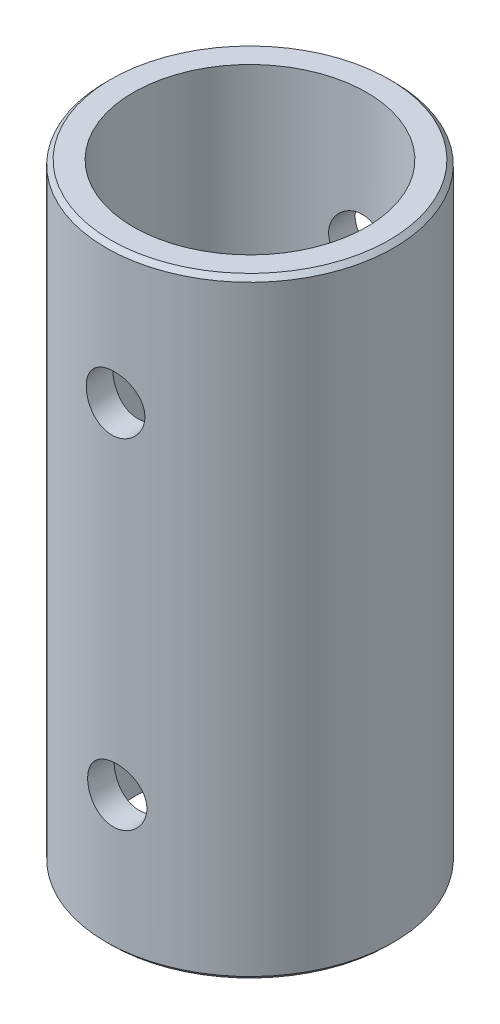
from build123d import *

# Parameters (mm, degrees)
SKETCH1_R               = 7.94
SKETCH1_R_2             = 6.44
BOSS_EXTRUDE1_DEPTH     = 33.7
CHAMFER1_SIZE           = 0.25
SKETCH2_R               = 1.55
SKETCH2_RX              = 1.55
SKETCH2_RY              = 1.54981566
CUT_EXTRUDE1_DEPTH      = 3.443979861
CUT_EXTRUDE1_DEPTH_BACK = 15.143979861


with BuildPart() as part:
    # Sketch1 → Boss-Extrude1 (new body)
    with BuildSketch(Plane(origin=(0, 0, 0), x_dir=(1, 0, 0), z_dir=(0, 1, 0))):
        Circle(SKETCH1_R)
        Circle(SKETCH1_R_2, mode=Mode.SUBTRACT)
    extrude(amount=BOSS_EXTRUDE1_DEPTH)

    # Chamfer1
    chamfer1_edges = [part.edges().sort_by_distance(p)[0] for p in [
        (-7.94, 0, 0),
        (-7.94, 33.7, 0),
    ]]
    chamfer(chamfer1_edges, length=CHAMFER1_SIZE)

    # Sketch2 → Cut-Extrude1 (cut, two sides)
    with BuildSketch(Plane(origin=(0.266895271, 0, 5.843908531), x_dir=(0.998958723, 0, -0.045623123), z_dir=(0.045623123, 0, 0.998958723))) as cut_extrude1_sk:
        with Locations((0, 26.2)):
            Circle(SKETCH2_R)
        with Locations(Location((0.090219685, 7.5), (0, 0, 90))):
            Ellipse(SKETCH2_RX, SKETCH2_RY)
    extrude(amount=CUT_EXTRUDE1_DEPTH, mode=Mode.SUBTRACT)
    extrude(cut_extrude1_sk.sketch, amount=-CUT_EXTRUDE1_DEPTH_BACK, mode=Mode.SUBTRACT)


solid = part.part
